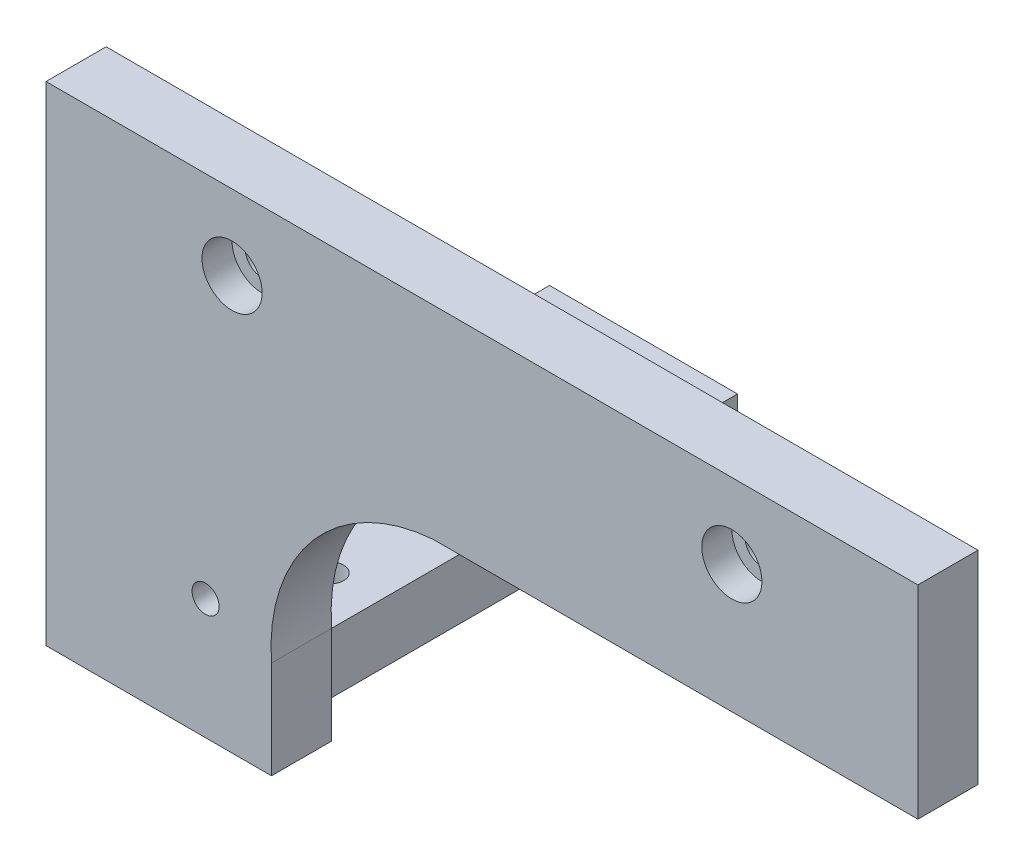
from build123d import *

# Parameters (mm, degrees)
SKETCH_1_R          = 1.8
EXTRUDE_1_DEPTH     = 8
SKETCH_3_R          = 2.25
CUT_EXTRUDE_1_DEPTH = 9
SKETCH_5_R          = 1.8
EXTRUDE_3_DEPTH     = 8
SKETCH_17_R         = 1.8
CUT_EXTRUDE_8_DEPTH = 10
SKETCH_18_R         = 4
CUT_EXTRUDE_9_DEPTH = 4


with BuildPart() as part:
    # 草图1 → 凸台-拉伸1 (new body)
    with BuildSketch(Plane.XY):
        with BuildLine():
            Line((58, 13.5), (58, -13.5))
            Line((58, -13.5), (-6.5, -13.5))
            ThreePointArc((-6.5, -13.5), (-22.42766953, -21.547204204), (-28, -38.5))
            Line((-28, -38.5), (-28, -43.5))
            Line((-28, -43.5), (-58, -43.5))
            Line((-58, -43.5), (-58, 13.5))
            Line((-58, 13.5), (58, 13.5))
        make_face()
        with Locations((-36.769098454, -35.48436381)):
            Circle(SKETCH_1_R, mode=Mode.SUBTRACT)
    extrude(amount=EXTRUDE_1_DEPTH)

    # 草图3 → 切除-拉伸1 (cut, through all)
    with BuildSketch(Plane.XY.offset(8)):
        with Locations((-33.25, 3.5)):
            Circle(SKETCH_3_R)
        with Locations((33.25, 3.5)):
            Circle(SKETCH_3_R)
    extrude(amount=-CUT_EXTRUDE_1_DEPTH, mode=Mode.SUBTRACT)

    # 草图5 → 凸台-拉伸3 (add)
    with BuildSketch(Plane.XZ.offset(43.5)):
        with BuildLine():
            Line((-33, -59), (-58, -59))
            Line((-58, -59), (-58, 8))
            Line((-58, 8), (-28, 8))
            Line((-28, 8), (-28, 0))
            ThreePointArc((-28, 0), (-31.434237008, -1.219913748), (-33, -4.510895309))
            Line((-33, -4.510895309), (-33, -59))
        make_face()
        with Locations((-49.676985034, -44.88768769)):
            Circle(SKETCH_5_R, mode=Mode.SUBTRACT)
        with Locations((-39.676985034, -44.88768769)):
            Circle(SKETCH_5_R, mode=Mode.SUBTRACT)
    extrude(amount=EXTRUDE_3_DEPTH)

    # 草图17 → 切除-拉伸8 (cut)
    with BuildSketch(Plane.XZ.offset(51.5)):
        with Locations((-39.481532593, -11.284064148)):
            Circle(SKETCH_17_R)
    extrude(amount=-CUT_EXTRUDE_8_DEPTH, mode=Mode.SUBTRACT)

    # 草图18 → 切除-拉伸9 (cut)
    with BuildSketch(Plane.XY.offset(8)):
        with Locations((-33.25, 3.5)):
            Circle(SKETCH_18_R)
        with Locations((33.25, 3.5)):
            Circle(SKETCH_18_R)
    extrude(amount=-CUT_EXTRUDE_9_DEPTH, mode=Mode.SUBTRACT)


solid = part.part
